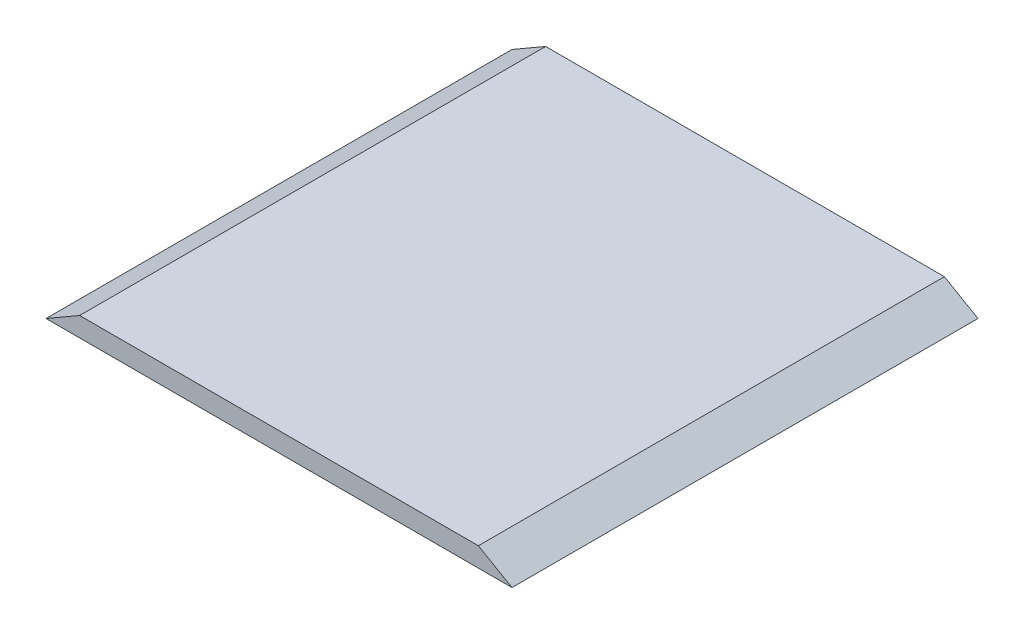
from build123d import *

# Parameters (mm, degrees)
SKETCH1_W           = 304.8
SKETCH1_H           = 304.8
BOSS_EXTRUDE1_DEPTH = 12.7
CUT_EXTRUDE1_DEPTH  = 305.8


with BuildPart() as part:
    # Sketch1 → Boss-Extrude1 (new body)
    with BuildSketch(Plane(origin=(0, 0, 0), x_dir=(1, 0, 0), z_dir=(0, 1, 0))):
        with Locations((152.4, -152.4)):
            Rectangle(SKETCH1_W, SKETCH1_H)
    extrude(amount=BOSS_EXTRUDE1_DEPTH)

    # Sketch2 → Cut-Extrude1 (cut, through all)
    with BuildSketch(Plane.XY.offset(304.8)):
        Polygon((0, 0), (21.997045256, 12.7), (0, 12.7), align=None)
        Polygon((304.8, 0), (282.802954744, 12.7), (304.8, 12.7), align=None)
    extrude(amount=-CUT_EXTRUDE1_DEPTH, mode=Mode.SUBTRACT)


solid = part.part
